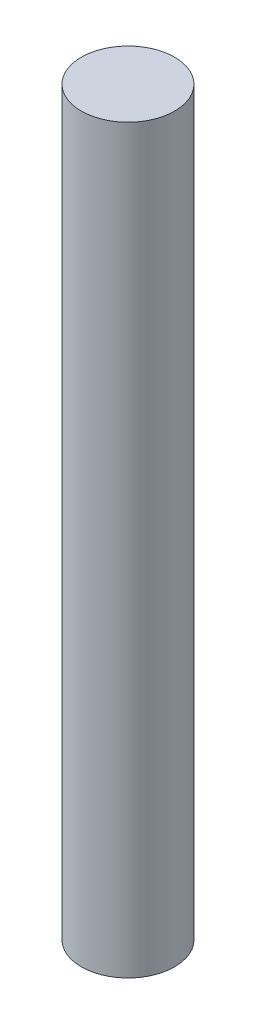
from build123d import *

# Parameters (mm, degrees)
SKETCH2_R           = 6.3
BOSS_EXTRUDE1_DEPTH = 100


with BuildPart() as part:
    # Sketch2 → Boss-Extrude1 (new body)
    with BuildSketch(Plane(origin=(0, 0, 0), x_dir=(1, 0, 0), z_dir=(0, 1, 0))):
        Circle(SKETCH2_R)
    extrude(amount=BOSS_EXTRUDE1_DEPTH)


solid = part.part
